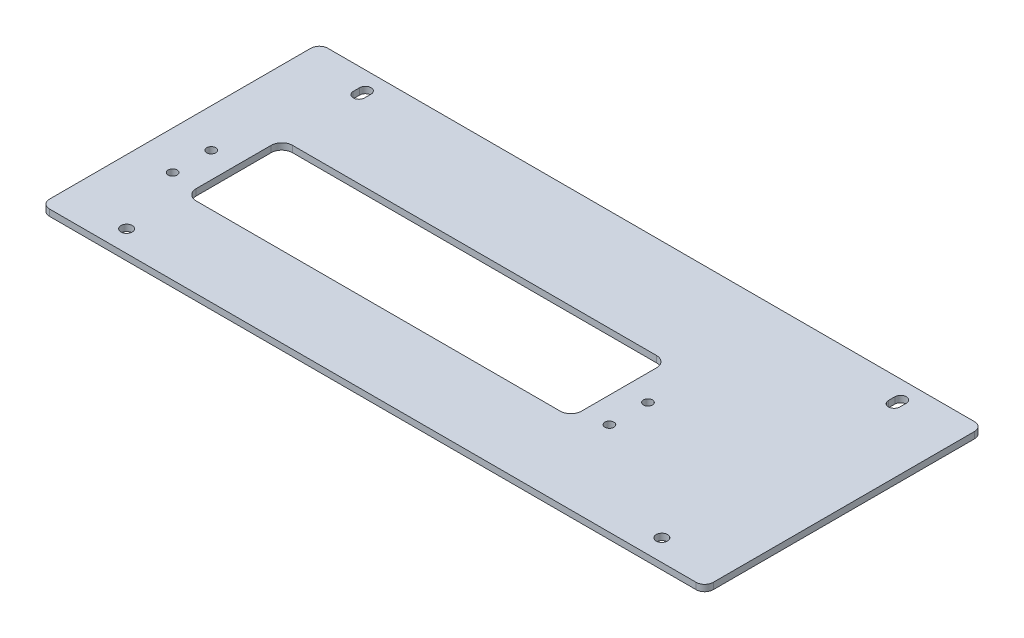
from build123d import *

# Parameters (mm, degrees)
SKETCH1_W                  = 310
SKETCH1_H                  = 130
BOSS_EXTRUDE1_DEPTH        = 3
FILLET1_R                  = 4
F_5_3_5_3_DIAMETER_HOLE1_D = 5.3
SKETCH6_W                  = 180
SKETCH6_H                  = 45
CUT_EXTRUDE1_DEPTH         = 4
FILLET2_R                  = 5
M5X0_8_TAPPED_HOLE1_D      = 4.2
CUT_EXTRUDE2_DEPTH         = 4


with BuildPart() as part:
    # Sketch1 → Boss-Extrude1 (new body)
    with BuildSketch(Plane(origin=(0, 0, 0), x_dir=(1, 0, 0), z_dir=(0, 1, 0))):
        Rectangle(SKETCH1_W, SKETCH1_H)
    extrude(amount=BOSS_EXTRUDE1_DEPTH)

    # Fillet1
    fillet1_edges = [part.edges().sort_by_distance(p)[0] for p in [
        (155, 1.5, 65),
        (-155, 1.5, 65),
        (-155, 1.5, -65),
        (155, 1.5, -65),
    ]]
    fillet(fillet1_edges, radius=FILLET1_R)

    # Ø5.3 (5.3) Diameter Hole1 (through all)
    with Locations(Plane(origin=(0, 3, 0), x_dir=(1, 0, 0), z_dir=(0, 1, 0))):
        with Locations((125, 55), (-125, -55), (-125, 55), (125, -55)):
            Hole(F_5_3_5_3_DIAMETER_HOLE1_D / 2)

    # Sketch6 → Cut-Extrude1 (cut, through all)
    with BuildSketch(Plane(origin=(0, 3, 0), x_dir=(1, 0, 0), z_dir=(0, 1, 0))):
        with Locations((-35, -5)):
            Rectangle(SKETCH6_W, SKETCH6_H)
    extrude(amount=-CUT_EXTRUDE1_DEPTH, mode=Mode.SUBTRACT)

    # Fillet2
    fillet2_edges = [part.edges().sort_by_distance(p)[0] for p in [
        (55, 1.5, -17.5),
        (55, 1.5, 27.5),
        (-125, 1.5, 27.5),
        (-125, 1.5, -17.5),
    ]]
    fillet(fillet2_edges, radius=FILLET2_R)

    # M5x0.8 Tapped Hole1 (through all)
    with Locations(Plane(origin=(0, 3, 0), x_dir=(1, 0, 0), z_dir=(0, 1, 0))):
        with Locations((67, -3.5), (-137, -21.5), (-137, -3.5), (67, -21.5)):
            Hole(M5X0_8_TAPPED_HOLE1_D / 2)

    # Sketch9 → Cut-Extrude2 (cut, through all)
    with BuildSketch(Plane(origin=(0, 3, 0), x_dir=(1, 0, 0), z_dir=(0, 1, 0))):
        with BuildLine():
            Line((-127.65, 53.5), (-127.65, 56.5))
            ThreePointArc((-127.65, 56.5), (-125, 59.15), (-122.35, 56.5))
            Line((-122.35, 56.5), (-122.35, 53.5))
            ThreePointArc((-122.35, 53.5), (-125, 50.85), (-127.65, 53.5))
        make_face()
        with BuildLine():
            Line((122.35, 53.5), (122.35, 56.5))
            ThreePointArc((122.35, 56.5), (125, 59.15), (127.65, 56.5))
            Line((127.65, 56.5), (127.65, 53.5))
            ThreePointArc((127.65, 53.5), (125, 50.85), (122.35, 53.5))
        make_face()
    extrude(amount=-CUT_EXTRUDE2_DEPTH, mode=Mode.SUBTRACT)


solid = part.part
